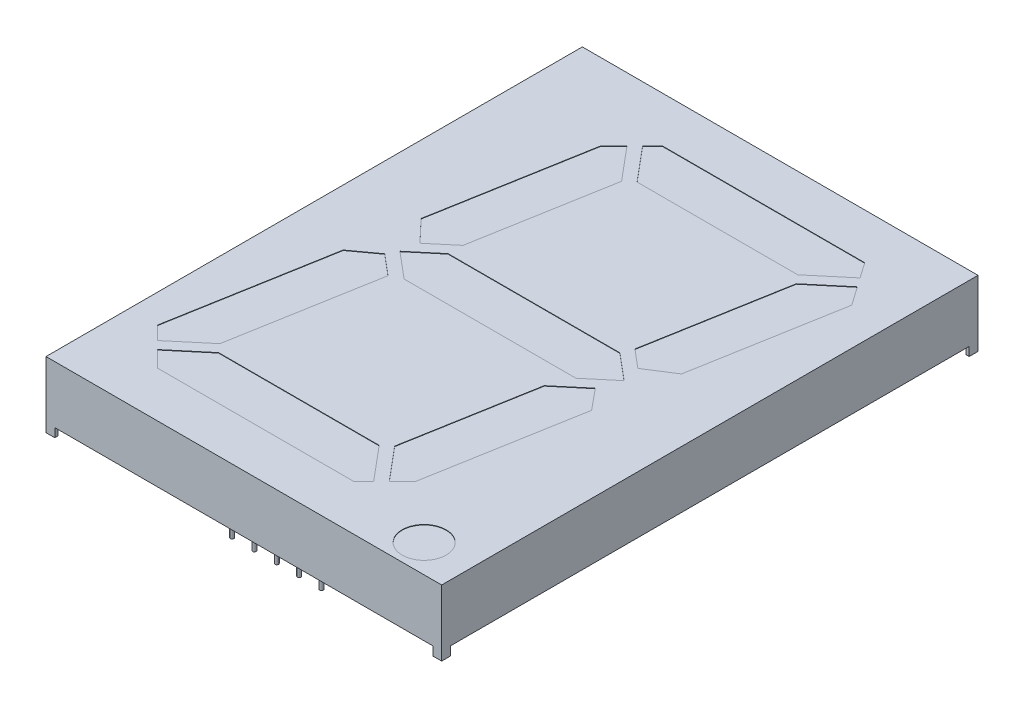
from build123d import *

# Parameters (mm, degrees)
SKETCH1_W          = 90
SKETCH1_H          = 122
EXTRUDE2_DEPTH     = 15
SKETCH2_W          = 43
SKETCH2_H          = 2
CUT_EXTRUDE2_DEPTH = 131.896905999
SKETCH3_W          = 118
SKETCH3_H          = 2
CUT_EXTRUDE3_DEPTH = 110.754270988
SKETCH6_R          = 5
CUT_EXTRUDE4_DEPTH = 0.1
SKETCH7_W          = 1.3
SKETCH7_H          = 1.3
CUT_EXTRUDE6_DEPTH = 2
SKETCH7_3_R        = 0.4
EXTRUDE3_DEPTH     = 2
SKETCH7_4_R        = 0.4
SKETCH7_4_W        = 1.3
SKETCH7_4_H        = 1.3
EXTRUDE4_DEPTH     = 7
SKETCH8_W          = 0.025316456
SKETCH8_H          = 0.026582279
CUT_EXTRUDE7_DEPTH = 0.01


with BuildPart() as part:
    # Sketch1 → Extrude2 (new body)
    with BuildSketch(Plane(origin=(0, 0, 0), x_dir=(1, 0, 0), z_dir=(0, 1, 0))):
        Rectangle(SKETCH1_W, SKETCH1_H)
    extrude(amount=-EXTRUDE2_DEPTH)

    # Sketch2 → Cut-Extrude2 (cut, through all)
    with BuildSketch(Plane.XY.offset(61)):
        with Locations((-21.5, -14)):
            Rectangle(SKETCH2_W, SKETCH2_H)
        with Locations((21.5, -14)):
            Rectangle(SKETCH2_W, SKETCH2_H)
    extrude(amount=-CUT_EXTRUDE2_DEPTH, mode=Mode.SUBTRACT)

    # Sketch3 → Cut-Extrude3 (cut, through all)
    with BuildSketch(Plane(origin=(45, 0, 0), x_dir=(0, 0, -1), z_dir=(1, 0, 0))):
        with Locations((0, -14)):
            Rectangle(SKETCH3_W, SKETCH3_H)
    extrude(amount=-CUT_EXTRUDE3_DEPTH, mode=Mode.SUBTRACT)

    # Sketch6 → Cut-Extrude4 (cut)
    with BuildSketch(Plane(origin=(0, 0, 0), x_dir=(-1, 0, 0), z_dir=(0, 1, 0))):
        Polygon((20.398345091, -46.545838518), (23.415251421, -43.528932188), (29.529286166, -8.854518093), (24.79846292, -3.852177728), (19.468462602, -8.324579029), (14.060787068, -38.993030976), align=None)
        Polygon((-29.633271507, -50.6), (16.344183609, -50.6), (18.623825555, -48.320358054), (12.14567596, -40.6), (-24.387261314, -40.6), (-32.102377523, -47.073751165), align=None)
        Polygon((26.725051062, 2.235578329), (32.183769067, 6.199802522), (38.516537786, 42.114718626), (35.472616354, 45.158640057), (27.757500146, 38.684888892), (22.025787113, 6.178728975), align=None)
        Polygon((19.541232037, -5), (25.5, 0), (19.541232037, 5), (-19.541232037, 5), (-25.5, 0), (-19.541232037, -5), align=None)
        Polygon((-36.516188743, -40.770175469), (-33.541796036, -45.018048485), (-25.994230339, -38.684888892), (-20.489778805, -7.46759298), (-24.644949642, -3.980990664), (-30.711693127, -7.851245007), align=None)
        Polygon((26.150531121, 40.6), (33.698096819, 46.933159593), (30.031256412, 50.6), (-14.580913802, 50.6), (-16.860555748, 48.320358054), (-10.382406153, 40.6), align=None)
        Polygon((-21.651981614, 43.528932188), (-27.647170865, 9.528524382), (-23.705923804, 4.768926898), (-17.399004207, 10.061060806), (-12.297517261, 38.993030976), (-18.635075284, 46.545838518), align=None)
        with Locations(Location((-34.625564691, 54.608682938, 0), (0, 0, 270))):
            Circle(SKETCH6_R)
    extrude(amount=-CUT_EXTRUDE4_DEPTH, mode=Mode.SUBTRACT)

    # Sketch7 → Cut-Extrude6 (cut)
    with BuildSketch(Plane.XZ.offset(15)):
        with Locations((-43.65, 59.65)):
            Rectangle(SKETCH7_W, SKETCH7_H)
        with Locations((-43.65, -59.65)):
            Rectangle(SKETCH7_W, SKETCH7_H)
        with Locations((43.65, -59.65)):
            Rectangle(SKETCH7_W, SKETCH7_H)
        with Locations((43.65, 59.65)):
            Rectangle(SKETCH7_W, SKETCH7_H)
    extrude(amount=-CUT_EXTRUDE6_DEPTH, mode=Mode.SUBTRACT)

    # Sketch7_3 → Extrude3 (add)
    with BuildSketch(Plane.XZ.offset(15)):
        with Locations(Location((-10.16, 53.5, 0), (0, 0, 270))):
            Circle(SKETCH7_3_R)
        with Locations(Location((-5.08, 53.5, 0), (0, 0, 270))):
            Circle(SKETCH7_3_R)
        with Locations(Location((0, 53.5, 0), (0, 0, 270))):
            Circle(SKETCH7_3_R)
        with Locations(Location((10.16, 53.5, 0), (0, 0, 270))):
            Circle(SKETCH7_3_R)
        with Locations(Location((5.08, 53.5, 0), (0, 0, 270))):
            Circle(SKETCH7_3_R)
        with Locations(Location((5.08, -53.5, 0), (0, 0, 270))):
            Circle(SKETCH7_3_R)
        with Locations(Location((10.16, -53.5, 0), (0, 0, 270))):
            Circle(SKETCH7_3_R)
        with Locations(Location((0, -53.5, 0), (0, 0, 270))):
            Circle(SKETCH7_3_R)
        with Locations(Location((-5.08, -53.5, 0), (0, 0, 270))):
            Circle(SKETCH7_3_R)
        with Locations(Location((-10.16, -53.5, 0), (0, 0, 270))):
            Circle(SKETCH7_3_R)
    extrude(amount=-EXTRUDE3_DEPTH)


with BuildPart() as extrude4_tool:
    # Sketch7_4 → Extrude4 (new body)
    with BuildSketch(Plane.XZ.offset(15)):
        with Locations(Location((-10.16, 53.5, 0), (0, 0, 270))):
            Circle(SKETCH7_4_R)
        with Locations(Location((-5.08, 53.5, 0), (0, 0, 270))):
            Circle(SKETCH7_4_R)
        with Locations(Location((0, 53.5, 0), (0, 0, 270))):
            Circle(SKETCH7_4_R)
        with Locations(Location((10.16, 53.5, 0), (0, 0, 270))):
            Circle(SKETCH7_4_R)
        with Locations(Location((5.08, 53.5, 0), (0, 0, 270))):
            Circle(SKETCH7_4_R)
        with Locations(Location((5.08, -53.5, 0), (0, 0, 270))):
            Circle(SKETCH7_4_R)
        with Locations(Location((10.16, -53.5, 0), (0, 0, 270))):
            Circle(SKETCH7_4_R)
        with Locations(Location((0, -53.5, 0), (0, 0, 270))):
            Circle(SKETCH7_4_R)
        with Locations(Location((-5.08, -53.5, 0), (0, 0, 270))):
            Circle(SKETCH7_4_R)
        with Locations(Location((-10.16, -53.5, 0), (0, 0, 270))):
            Circle(SKETCH7_4_R)
        with Locations((-43.65, 59.65)):
            Rectangle(SKETCH7_4_W, SKETCH7_4_H)
        with Locations((-43.65, -59.65)):
            Rectangle(SKETCH7_4_W, SKETCH7_4_H)
        with Locations((43.65, -59.65)):
            Rectangle(SKETCH7_4_W, SKETCH7_4_H)
        with Locations((43.65, 59.65)):
            Rectangle(SKETCH7_4_W, SKETCH7_4_H)
    extrude(amount=EXTRUDE4_DEPTH)


with BuildPart() as part_1:
    add(part.part)


with BuildPart() as part_2:
    # Extrude4: joined with extrude4_tool
    add(part_1.part.fuse(extrude4_tool.part, tol=0.00001))


with BuildPart() as extrude4_kept_piece:
    # of the separate pieces the step leaves, the one the design keeps (extrude4_pieces_kept)
    add(part_2.part.solids().sort_by_distance((-45, 0, -61))[0])

    # Sketch8 → Cut-Extrude7 (cut)
    with BuildSketch(Plane.XZ.offset(13)):
        Polygon((0.898234135, 43.968770201), (0.921691414, 44.043453745), (0.946434294, 44.043453745), (0.962850433, 43.993117511), (0.97837654, 44.043453745), (1.004108344, 44.043453745), (1.027348059, 43.968770201), (1.002170053, 43.968770201), (0.989175591, 44.020253587), (0.972759452, 43.968770201), (0.951260243, 43.968770201), (0.934942996, 44.020253587), (0.92212654, 43.968770201), align=None)
        Polygon((0.76405692, 43.968770201), (0.787514199, 44.043453745), (0.812257078, 44.043453745), (0.828673218, 43.993117511), (0.844199325, 44.043453745), (0.869931129, 44.043453745), (0.893170844, 43.968770201), (0.867992838, 43.968770201), (0.854998376, 44.020253587), (0.838582237, 43.968770201), (0.817083028, 43.968770201), (0.800765781, 44.020253587), (0.787949325, 43.968770201), align=None)
        Polygon((0.629879705, 43.968770201), (0.653336984, 44.043453745), (0.678079863, 44.043453745), (0.694496003, 43.993117511), (0.71002211, 44.043453745), (0.735753914, 44.043453745), (0.758993629, 43.968770201), (0.733815623, 43.968770201), (0.720821161, 44.020253587), (0.704405022, 43.968770201), (0.682905813, 43.968770201), (0.666588566, 44.020253587), (0.65377211, 43.968770201), align=None)
        with Locations((0.602031604, 44.030162606)):
            Rectangle(SKETCH8_W, SKETCH8_H)
        with BuildLine():
            add(Edge.make_bspline(
                [(0.485575908, 44.012282859), (0.485612436, 44.013504973), (0.485684165, 44.015904797), (0.486293327, 44.019412763), (0.487288851, 44.022736046), (0.488653189, 44.025898762), (0.490467177, 44.028854128), (0.492622191, 44.031672695), (0.495234105, 44.034256657), (0.498171141, 44.036695418), (0.501469069, 44.038877813), (0.50507169, 44.040777951), (0.50894201, 44.04240267), (0.513096031, 44.043734359), (0.517541609, 44.044725127), (0.522259385, 44.045448444), (0.527252734, 44.045921952), (0.530676322, 44.045963893), (0.532431129, 44.04598539)],
                knots=[0, 0, 0, 0, 0.907421153, 1.781872267, 2.635683434, 3.480115191, 4.332689235, 5.205575272, 6.109500117, 7.055808355, 8.037942167, 9.041423561, 10.07750834, 11.152467461, 12.277657752, 13.45734338, 14.696726425, 16, 16, 16, 16], degree=3))
            add(Edge.make_bspline(
                [(0.532431129, 44.04598539), (0.534449114, 44.045958125), (0.5383573, 44.045905322), (0.544024868, 44.045519949), (0.549288334, 44.044831999), (0.554186081, 44.043875419), (0.558790382, 44.042672134), (0.563223726, 44.04138149), (0.567505019, 44.039916909), (0.570278111, 44.038816773), (0.571651857, 44.038271783)],
                knots=[0, 0, 0, 0, 1.203182053, 2.33017619, 3.384818652, 4.366208123, 5.30340534, 6.221361684, 7.118890722, 8, 8, 8, 8], degree=3))
            Line((0.571651857, 44.038271783), (0.571651857, 44.014339821))
            Line((0.571651857, 44.014339821), (0.568803756, 44.014339821))
            add(Edge.make_bspline(
                [(0.568803756, 44.014339821), (0.567438192, 44.015420783), (0.564715083, 44.017576363), (0.560288125, 44.020344717), (0.555629113, 44.022717727), (0.550790719, 44.02470035), (0.545889351, 44.026275964), (0.541020283, 44.02740287), (0.5362513, 44.028142234), (0.533092979, 44.028223795), (0.531541097, 44.028263871)],
                knots=[0, 0, 0, 0, 1.030738938, 2.055426519, 3.085610749, 4.123842265, 5.148648843, 6.130724483, 7.081507926, 8, 8, 8, 8], degree=3))
            add(Edge.make_bspline(
                [(0.531541097, 44.028263871), (0.531112351, 44.028262571), (0.530194439, 44.028259786), (0.528725291, 44.028138471), (0.527068947, 44.028010627), (0.525288209, 44.027814513), (0.523501004, 44.027583368), (0.521840757, 44.027236901), (0.520339995, 44.02686775), (0.519433326, 44.026500484), (0.51900154, 44.02632558)],
                knots=[0, 0, 0, 0, 0.806537132, 1.726733348, 2.77251655, 3.932999672, 5.098049949, 6.161349231, 7.124375527, 8, 8, 8, 8], degree=3))
            add(Edge.make_bspline(
                [(0.51900154, 44.02632558), (0.518522054, 44.026097345), (0.517579762, 44.025648813), (0.516277231, 44.024834903), (0.515106746, 44.023940158), (0.514046044, 44.022978425), (0.513183648, 44.021815437), (0.512562487, 44.020416166), (0.512217917, 44.018766873), (0.512178845, 44.017591711), (0.512158186, 44.016970359)],
                knots=[0, 0, 0, 0, 1.02474257, 2.013837243, 2.958431669, 3.867978675, 4.769292696, 5.732237074, 6.800947934, 8, 8, 8, 8], degree=3))
            add(Edge.make_bspline(
                [(0.512158186, 44.016970359), (0.512189647, 44.016424492), (0.51225151, 44.015351158), (0.512833016, 44.013822729), (0.513717062, 44.012402593), (0.514996478, 44.011137257), (0.516610156, 44.010011145), (0.518541143, 44.009000382), (0.520814994, 44.008164624), (0.522452207, 44.007726752), (0.523313249, 44.007496466)],
                knots=[0, 0, 0, 0, 0.825427492, 1.623033598, 2.45033906, 3.348940377, 4.33183287, 5.428402891, 6.647546779, 8, 8, 8, 8], degree=3))
            add(Edge.make_bspline(
                [(0.523313249, 44.007496466), (0.52528249, 44.007051262), (0.529317702, 44.006138984), (0.535457515, 44.00495153), (0.541596217, 44.003725659), (0.545552474, 44.002511344), (0.547482553, 44.001918935)],
                knots=[0, 0, 0, 0, 0.976118991, 2.000185432, 3.024380873, 4, 4, 4, 4], degree=3))
            add(Edge.make_bspline(
                [(0.547482553, 44.001918935), (0.548520706, 44.001565212), (0.550541568, 44.000876657), (0.55344076, 43.999724009), (0.556084007, 43.998418875), (0.558541547, 43.997096837), (0.56073421, 43.995616779), (0.562728844, 43.99408402), (0.564481505, 43.992431215), (0.566007943, 43.990681723), (0.567350809, 43.988845361), (0.568504218, 43.98689822), (0.569465241, 43.98483177), (0.570288633, 43.982676373), (0.570899859, 43.980401838), (0.571322296, 43.978025421), (0.571620359, 43.975541934), (0.571641215, 43.973847599), (0.571651857, 43.972983017)],
                knots=[0, 0, 0, 0, 1.287376879, 2.505999703, 3.65855109, 4.746193839, 5.778582289, 6.760029101, 7.696159662, 8.601061861, 9.48181646, 10.363080883, 11.252765705, 12.153987336, 13.068239035, 14.012364187, 14.985753787, 16, 16, 16, 16], degree=3))
            add(Edge.make_bspline(
                [(0.571651857, 43.972983017), (0.571614557, 43.971826871), (0.57154115, 43.969551596), (0.5709397, 43.966222573), (0.569913189, 43.963073755), (0.56852683, 43.960070598), (0.566699337, 43.957256335), (0.564507214, 43.954578849), (0.561896904, 43.952086353), (0.558911577, 43.949787716), (0.555624729, 43.947708911), (0.552090724, 43.945872203), (0.548311873, 43.944365756), (0.544331988, 43.943084525), (0.540112595, 43.942132129), (0.535675625, 43.941412551), (0.531001762, 43.940999551), (0.527810351, 43.940948276), (0.526181129, 43.940922099)],
                knots=[0, 0, 0, 0, 0.894901293, 1.761149761, 2.608783409, 3.453876344, 4.314933854, 5.200038827, 6.12799933, 7.103249695, 8.113098521, 9.136064399, 10.182719798, 11.259667356, 12.370545059, 13.528828137, 14.738461593, 16, 16, 16, 16], degree=3))
            add(Edge.make_bspline(
                [(0.526181129, 43.940922099), (0.524512477, 43.940944492), (0.521178004, 43.940989239), (0.516196031, 43.941364209), (0.511238616, 43.94193071), (0.506367052, 43.942730165), (0.501684545, 43.94374782), (0.497267931, 43.944833779), (0.493188961, 43.946074168), (0.490615236, 43.947028214), (0.489373376, 43.947488555)],
                knots=[0, 0, 0, 0, 1.065379838, 2.128953261, 3.188461447, 4.250817766, 5.279613205, 6.247547721, 7.154416075, 8, 8, 8, 8], degree=3))
            Line((0.489373376, 43.947488555), (0.489373376, 43.970036023))
            Line((0.489373376, 43.970036023), (0.492201699, 43.970036023))
            add(Edge.make_bspline(
                [(0.492201699, 43.970036023), (0.493274658, 43.969235819), (0.495468889, 43.967599382), (0.499127641, 43.965513405), (0.503091702, 43.963563891), (0.507356603, 43.961842097), (0.511829144, 43.960421497), (0.51640669, 43.959392453), (0.521033755, 43.958753329), (0.524135346, 43.958680197), (0.525686667, 43.958643618)],
                knots=[0, 0, 0, 0, 0.89224925, 1.824673196, 2.804309561, 3.838364047, 4.890042674, 5.931526337, 6.965412421, 8, 8, 8, 8], degree=3))
            add(Edge.make_bspline(
                [(0.525686667, 43.958643618), (0.526781967, 43.958667828), (0.528971712, 43.958716229), (0.53224612, 43.959065483), (0.535480911, 43.959737224), (0.53752381, 43.96055156), (0.53854268, 43.960957701)],
                knots=[0, 0, 0, 0, 0.998993879, 1.997209027, 3.00113285, 4, 4, 4, 4], degree=3))
            add(Edge.make_bspline(
                [(0.53854268, 43.960957701), (0.538976159, 43.961159183), (0.539842828, 43.961562014), (0.541049832, 43.96233434), (0.542153135, 43.963264058), (0.543154141, 43.964316452), (0.544002197, 43.965485787), (0.544639857, 43.966755546), (0.545000676, 43.968117525), (0.545046513, 43.969051693), (0.545069578, 43.969521783)],
                knots=[0, 0, 0, 0, 1.005454979, 2.010239304, 3.005296729, 4.036100111, 5.060531193, 6.034954812, 7.011155677, 8, 8, 8, 8], degree=3))
            add(Edge.make_bspline(
                [(0.545069578, 43.969521783), (0.545034784, 43.970159714), (0.544968295, 43.971378742), (0.544368298, 43.973092438), (0.543370629, 43.97455555), (0.54221753, 43.975548543), (0.541100551, 43.976247303), (0.540060034, 43.976752542), (0.538860583, 43.977265965), (0.537483134, 43.977755163), (0.535947999, 43.978249209), (0.534239076, 43.978723879), (0.532356469, 43.979173438), (0.531040578, 43.97945959), (0.530354389, 43.979608808)],
                knots=[0, 0, 0, 0, 1.174343879, 2.244064321, 3.303704314, 4.407076671, 5.02483983, 5.732197225, 6.53898402, 7.431906431, 8.428480183, 9.514816237, 10.704066255, 12, 12, 12, 12], degree=3))
            add(Edge.make_bspline(
                [(0.530354389, 43.979608808), (0.528521764, 43.979985528), (0.524921061, 43.9807257), (0.519515986, 43.981819997), (0.514022932, 43.983132514), (0.510352382, 43.984261726), (0.508439832, 43.984850106)],
                knots=[0, 0, 0, 0, 0.995788186, 1.956503735, 2.935230479, 4, 4, 4, 4], degree=3))
            add(Edge.make_bspline(
                [(0.508439832, 43.984850106), (0.507493275, 43.985169347), (0.505641658, 43.985793835), (0.50300106, 43.986880153), (0.500553886, 43.98805401), (0.498287252, 43.989295979), (0.496211887, 43.990638413), (0.494325597, 43.992063746), (0.49262764, 43.993568529), (0.491138891, 43.995184249), (0.489810134, 43.996894597), (0.48869779, 43.99874521), (0.487702204, 44.000688739), (0.48694905, 44.002782182), (0.48632454, 44.00498071), (0.485902798, 44.007312644), (0.485608435, 44.009756862), (0.485586871, 44.011431461), (0.485575908, 44.012282859)],
                knots=[0, 0, 0, 0, 1.237326419, 2.420410185, 3.534642089, 4.598489486, 5.620241961, 6.59385002, 7.525152549, 8.426792174, 9.312230456, 10.203151844, 11.098070343, 12.012931196, 12.954244379, 13.926618287, 14.945853925, 16, 16, 16, 16], degree=3))
        make_face()
        with BuildLine():
            Line((0.393170844, 44.043453745), (0.417221477, 44.043453745))
            Line((0.417221477, 44.043453745), (0.417221477, 44.035621466))
            add(Edge.make_bspline(
                [(0.417221477, 44.035621466), (0.418314671, 44.036430261), (0.420422333, 44.037989606), (0.423596892, 44.040066667), (0.426615192, 44.04185109), (0.429545544, 44.043374207), (0.432551821, 44.044586378), (0.435789955, 44.045404758), (0.439291551, 44.045907482), (0.441718621, 44.045958844), (0.442973059, 44.04598539)],
                knots=[0, 0, 0, 0, 1.150945962, 2.219006967, 3.209666795, 4.118194914, 5.012574058, 5.946577101, 6.93868214, 8, 8, 8, 8], degree=3))
            add(Edge.make_bspline(
                [(0.442973059, 44.04598539), (0.443989334, 44.045962443), (0.445968315, 44.045917756), (0.448846615, 44.045576036), (0.451548581, 44.045027627), (0.454077418, 44.04425922), (0.456427118, 44.043256189), (0.458570798, 44.041984554), (0.460573375, 44.040551841), (0.462355322, 44.038845475), (0.463970868, 44.036947557), (0.465353439, 44.034815148), (0.466531144, 44.032482208), (0.467472244, 44.029930358), (0.468227332, 44.027172053), (0.468751265, 44.024192806), (0.469071857, 44.021005679), (0.469103797, 44.018810548), (0.469120211, 44.017682384)],
                knots=[0, 0, 0, 0, 1.108959949, 2.159465255, 3.158589008, 4.114545495, 5.039534357, 5.93921201, 6.830099133, 7.720870013, 8.624681761, 9.544731627, 10.487599671, 11.471264588, 12.508152322, 13.604835107, 14.769030043, 16, 16, 16, 16], degree=3))
            Line((0.469120211, 44.017682384), (0.469120211, 43.968770201))
            Line((0.469120211, 43.968770201), (0.445069578, 43.968770201))
            Line((0.445069578, 43.968770201), (0.445069578, 44.006349314))
            add(Edge.make_bspline(
                [(0.445069578, 44.006349314), (0.445067943, 44.007265785), (0.445064812, 44.009020001), (0.444982474, 44.011525808), (0.444861573, 44.01379398), (0.444722868, 44.015836009), (0.444469852, 44.01768276), (0.444092143, 44.019348921), (0.443621317, 44.020868522), (0.443156998, 44.021775224), (0.442933503, 44.022211656)],
                knots=[0, 0, 0, 0, 1.361401701, 2.605856924, 3.723918663, 4.735739235, 5.645738665, 6.489217889, 7.27279937, 8, 8, 8, 8], degree=3))
            add(Edge.make_bspline(
                [(0.442933503, 44.022211656), (0.442703494, 44.022610362), (0.442251317, 44.023394183), (0.441331053, 44.024400494), (0.44025221, 44.025244245), (0.438975007, 44.025902346), (0.43748544, 44.026392849), (0.435764581, 44.02677342), (0.433772839, 44.026945298), (0.432365371, 44.026979788), (0.431620211, 44.026998049)],
                knots=[0, 0, 0, 0, 0.849004071, 1.669068917, 2.503060811, 3.370079215, 4.310762265, 5.396376419, 6.621555549, 8, 8, 8, 8], degree=3))
            add(Edge.make_bspline(
                [(0.431620211, 44.026998049), (0.431079269, 44.02697821), (0.429967852, 44.026937448), (0.4282504, 44.026745907), (0.42646114, 44.026346748), (0.423942471, 44.025701804), (0.420777261, 44.024507949), (0.418417727, 44.023154802), (0.417221477, 44.022468777)],
                knots=[0, 0, 0, 0, 0.638062719, 1.310959128, 2.033463623, 2.796942592, 4.376095945, 6, 6, 6, 6], degree=3))
            Line((0.417221477, 44.022468777), (0.417221477, 43.968770201))
            Line((0.417221477, 43.968770201), (0.393170844, 43.968770201))
            Line((0.393170844, 43.968770201), (0.393170844, 44.043453745))
        make_face()
        with BuildLine():
            Line((0.29570249, 44.043453745), (0.319753123, 44.043453745))
            Line((0.319753123, 44.043453745), (0.319753123, 44.005874631))
            add(Edge.make_bspline(
                [(0.319753123, 44.005874631), (0.319778129, 44.004344641), (0.319828101, 44.00128715), (0.320104652, 43.997524056), (0.320489138, 43.994682516), (0.320856678, 43.992850928), (0.321288549, 43.991302811), (0.321700811, 43.990417049), (0.321889199, 43.990012289)],
                knots=[0, 0, 0, 0, 1.709111167, 3.415443484, 4.21113913, 4.910175115, 5.501990373, 6, 6, 6, 6], degree=3))
            add(Edge.make_bspline(
                [(0.321889199, 43.990012289), (0.32213366, 43.989614226), (0.322612959, 43.988833768), (0.32355031, 43.987820891), (0.324644094, 43.986991523), (0.32591527, 43.986312056), (0.327403379, 43.985832868), (0.329127296, 43.985480114), (0.331107481, 43.98526956), (0.332516309, 43.985241007), (0.333261825, 43.985225897)],
                knots=[0, 0, 0, 0, 0.860202684, 1.686548532, 2.528236983, 3.382486038, 4.33249885, 5.401154041, 6.624757403, 8, 8, 8, 8], degree=3))
            add(Edge.make_bspline(
                [(0.333261825, 43.985225897), (0.334392714, 43.985285997), (0.33670041, 43.985408639), (0.33957572, 43.986075305), (0.341893058, 43.986935269), (0.343750774, 43.987685705), (0.345658496, 43.988659805), (0.346938039, 43.989381247), (0.347601224, 43.989755169)],
                knots=[0, 0, 0, 0, 1.33818541, 2.730705359, 3.468371228, 4.262126284, 5.099261778, 6, 6, 6, 6], degree=3))
            Line((0.347601224, 43.989755169), (0.347601224, 44.043453745))
            Line((0.347601224, 44.043453745), (0.371651857, 44.043453745))
            Line((0.371651857, 44.043453745), (0.371651857, 43.968770201))
            Line((0.371651857, 43.968770201), (0.347601224, 43.968770201))
            Line((0.347601224, 43.968770201), (0.347601224, 43.976602479))
            add(Edge.make_bspline(
                [(0.347601224, 43.976602479), (0.346543817, 43.975796327), (0.344485513, 43.974227105), (0.341306275, 43.972186685), (0.338222377, 43.970387916), (0.335169367, 43.968875099), (0.332054412, 43.967668324), (0.328791654, 43.966857335), (0.325375248, 43.966313532), (0.323038533, 43.966263839), (0.321849642, 43.966238555)],
                knots=[0, 0, 0, 0, 1.126119141, 2.192057864, 3.198061997, 4.149848529, 5.076251285, 6.021887753, 6.99356175, 8, 8, 8, 8], degree=3))
            add(Edge.make_bspline(
                [(0.321849642, 43.966238555), (0.320853377, 43.966263955), (0.31890849, 43.966313541), (0.316073641, 43.966623093), (0.313402534, 43.967174316), (0.31090915, 43.967970173), (0.308573464, 43.968961532), (0.306399792, 43.970165511), (0.304413943, 43.971628792), (0.302585791, 43.973288731), (0.300946691, 43.975180029), (0.299549781, 43.977309407), (0.298345419, 43.979646327), (0.297396154, 43.982208964), (0.29660483, 43.984975236), (0.296100066, 43.987973866), (0.295742413, 43.991183752), (0.295716064, 43.993399902), (0.29570249, 43.994541561)],
                knots=[0, 0, 0, 0, 1.08828964, 2.12453497, 3.110382522, 4.062402335, 4.978696626, 5.878225494, 6.769849763, 7.667011675, 8.57076823, 9.495541561, 10.442454184, 11.436213583, 12.475881554, 13.580560132, 14.753614518, 16, 16, 16, 16], degree=3))
            Line((0.29570249, 43.994541561), (0.29570249, 44.043453745))
        make_face()
        Polygon((0.200765781, 44.043453745), (0.27291768, 44.043453745), (0.27291768, 43.943453745), (0.247601224, 43.943453745), (0.247601224, 44.024466403), (0.200765781, 44.024466403), align=None)
        Polygon((0.113424009, 44.043453745), (0.185575908, 44.043453745), (0.185575908, 43.943453745), (0.113424009, 43.943453745), (0.113424009, 43.962441087), (0.160259452, 43.962441087), (0.160259452, 43.980162606), (0.117221477, 43.980162606), (0.117221477, 43.999149947), (0.160259452, 43.999149947), (0.160259452, 44.024466403), (0.113424009, 44.024466403), align=None)
        with BuildLine():
            add(Edge.make_bspline(
                [(-0.003031687, 43.993552637), (-0.003012372, 43.994700326), (-0.00297412, 43.996973212), (-0.002678929, 44.000338019), (-0.002152903, 44.003603694), (-0.001473722, 44.006787943), (-0.000551216, 44.009866871), (0.000530498, 44.012874448), (0.001840144, 44.015779941), (0.003344996, 44.018581376), (0.004994468, 44.021253478), (0.006769217, 44.023773687), (0.008614997, 44.026156905), (0.010604309, 44.028351799), (0.012683491, 44.030393818), (0.014859019, 44.032284633), (0.017164084, 44.033988063), (0.018771246, 44.035010948), (0.019575116, 44.035522574)],
                knots=[0, 0, 0, 0, 1.105570398, 2.18947457, 3.250358341, 4.290584537, 5.323553275, 6.344225964, 7.367641686, 8.3905646, 9.405808457, 10.390761353, 11.358902336, 12.307789878, 13.241960776, 14.165076779, 15.082208636, 16, 16, 16, 16], degree=3))
            add(Edge.make_bspline(
                [(0.019575116, 44.035522574), (0.020814303, 44.036234895), (0.023299001, 44.037663172), (0.027283459, 44.039329011), (0.031405068, 44.040743234), (0.035764248, 44.041756674), (0.04040297, 44.04252651), (0.045407781, 44.043074681), (0.050814687, 44.043380184), (0.05454968, 44.043428666), (0.056481762, 44.043453745)],
                knots=[0, 0, 0, 0, 0.896321744, 1.797216976, 2.705381885, 3.628777036, 4.602292017, 5.655629376, 6.787275635, 8, 8, 8, 8], degree=3))
            Line((0.056481762, 44.043453745), (0.091905022, 44.043453745))
            Line((0.091905022, 44.043453745), (0.091905022, 43.943453745))
            Line((0.091905022, 43.943453745), (0.055473059, 43.943453745))
            add(Edge.make_bspline(
                [(0.055473059, 43.943453745), (0.053494363, 43.943470555), (0.049677704, 43.943502979), (0.044160387, 43.943917907), (0.039058049, 43.94452367), (0.034368469, 43.945417856), (0.030066019, 43.946532437), (0.026148728, 43.947920968), (0.022532495, 43.949413585), (0.020353959, 43.950688139), (0.019298218, 43.951305802)],
                knots=[0, 0, 0, 0, 1.267083275, 2.444046388, 3.541868212, 4.55639609, 5.499737919, 6.385160515, 7.217431253, 8, 8, 8, 8], degree=3))
            add(Edge.make_bspline(
                [(0.019298218, 43.951305802), (0.018447264, 43.951842342), (0.01675514, 43.952909256), (0.014353925, 43.954691108), (0.012124498, 43.956647185), (0.009995995, 43.958699004), (0.008016177, 43.960901891), (0.006172978, 43.963240598), (0.004469161, 43.965718692), (0.002911197, 43.968328161), (0.001490382, 43.971058213), (0.000301076, 43.973931272), (-0.000748273, 43.976909802), (-0.001553809, 43.980018764), (-0.002251723, 43.983226601), (-0.002686458, 43.986567945), (-0.002973069, 43.990020433), (-0.003011983, 43.992365323), (-0.003031687, 43.993552637)],
                knots=[0, 0, 0, 0, 0.964065863, 1.917049184, 2.86229036, 3.805247319, 4.749389377, 5.698846072, 6.657678277, 7.629829384, 8.610569287, 9.604676042, 10.607940105, 11.6349849, 12.681042988, 13.752616828, 14.862056989, 16, 16, 16, 16], degree=3))
        make_face()
        with BuildLine():
            add(Edge.make_bspline(
                [(0.023550591, 43.993394409), (0.023593893, 43.991815979), (0.023677506, 43.98876818), (0.024382901, 43.984372536), (0.025522151, 43.980329586), (0.026859843, 43.977217169), (0.028197235, 43.974943852), (0.029324758, 43.973345582), (0.030574424, 43.971831382), (0.031965034, 43.970422542), (0.033500218, 43.969115506), (0.035161477, 43.967886595), (0.036961518, 43.966757949), (0.038234549, 43.966097944), (0.038878914, 43.965763871)],
                knots=[0, 0, 0, 0, 1.694683197, 3.272273219, 4.767406206, 6.197615014, 6.895990032, 7.597410435, 8.296503208, 9.002591366, 9.720792421, 10.460154445, 11.220583224, 12, 12, 12, 12], degree=3))
            add(Edge.make_bspline(
                [(0.038878914, 43.965763871), (0.039553849, 43.965457357), (0.040891617, 43.964849824), (0.042961893, 43.964115738), (0.045054594, 43.96355341), (0.047248822, 43.963080988), (0.049725581, 43.962803852), (0.052648073, 43.962591175), (0.056104746, 43.962454248), (0.058591341, 43.962445677), (0.059923218, 43.962441087)],
                knots=[0, 0, 0, 0, 0.826913061, 1.638999358, 2.447478739, 3.243919028, 4.140906711, 5.225381046, 6.513851968, 8, 8, 8, 8], degree=3))
            Line((0.059923218, 43.962441087), (0.066588566, 43.962441087))
            Line((0.066588566, 43.962441087), (0.066588566, 44.024466403))
            Line((0.066588566, 44.024466403), (0.059923218, 44.024466403))
            add(Edge.make_bspline(
                [(0.059923218, 44.024466403), (0.059165026, 44.024461357), (0.057701291, 44.024451616), (0.055584838, 44.024412514), (0.053620076, 44.024352197), (0.051812725, 44.024280355), (0.050156589, 44.024165451), (0.048668755, 44.023996855), (0.047326404, 44.023852467), (0.04575877, 44.023585348), (0.043905621, 44.023168893), (0.041744355, 44.022490801), (0.039603823, 44.021640382), (0.038215249, 44.020955418), (0.037514199, 44.020609599)],
                knots=[0, 0, 0, 0, 1.186775798, 2.291144404, 3.313233901, 4.263515562, 5.122260739, 5.910868134, 6.60717912, 7.234883681, 8.398964994, 9.577230746, 10.776813768, 12, 12, 12, 12], degree=3))
            add(Edge.make_bspline(
                [(0.037514199, 44.020609599), (0.036930485, 44.020266123), (0.035782548, 44.019590639), (0.034138403, 44.018484776), (0.032651664, 44.017249777), (0.031245602, 44.015966679), (0.029992736, 44.014576225), (0.028819442, 44.013125745), (0.027809187, 44.011563352), (0.026564192, 44.009369822), (0.02534446, 44.006336453), (0.0243037, 44.002369909), (0.023667185, 43.998009899), (0.023590451, 43.994972317), (0.023550591, 43.993394409)],
                knots=[0, 0, 0, 0, 0.755109416, 1.485004392, 2.205961541, 2.908125208, 3.605307969, 4.290649036, 4.985852759, 5.676964147, 7.100721462, 8.614478074, 10.241350405, 12, 12, 12, 12], degree=3))
        make_face(mode=Mode.SUBTRACT)
        with Locations((-0.034677257, 44.030162606)):
            Rectangle(SKETCH8_W, SKETCH8_H)
        with BuildLine():
            add(Edge.make_bspline(
                [(-0.109321244, 44.04598539), (-0.107731139, 44.045963564), (-0.104610017, 44.045920722), (-0.100038572, 44.045444021), (-0.095673769, 44.044725554), (-0.091526151, 44.043707382), (-0.087619589, 44.04235104), (-0.083938536, 44.040733025), (-0.080549174, 44.038715219), (-0.078485444, 44.037138278), (-0.077458111, 44.03635327)],
                knots=[0, 0, 0, 0, 1.123606455, 2.205459211, 3.245124445, 4.248821949, 5.220056174, 6.165006393, 7.086533249, 8, 8, 8, 8], degree=3))
            add(Edge.make_bspline(
                [(-0.077458111, 44.03635327), (-0.076506364, 44.035498496), (-0.074606549, 44.033792253), (-0.072140616, 44.030820826), (-0.070017531, 44.027537782), (-0.068231978, 44.02393556), (-0.066801054, 44.020018831), (-0.065777921, 44.015774169), (-0.065158675, 44.011213388), (-0.06509151, 44.008065454), (-0.065057004, 44.006448207)],
                knots=[0, 0, 0, 0, 0.916457077, 1.82937027, 2.759194969, 3.714948755, 4.706655623, 5.743329475, 6.840637961, 8, 8, 8, 8], degree=3))
            add(Edge.make_bspline(
                [(-0.065057004, 44.006448207), (-0.065095764, 44.00474498), (-0.065170887, 44.0014439), (-0.065834647, 43.996671712), (-0.066904259, 43.992254032), (-0.068441817, 43.988202123), (-0.070372259, 43.984508932), (-0.072636752, 43.981137097), (-0.075257278, 43.978094173), (-0.077264416, 43.976348733), (-0.078269029, 43.975475106)],
                knots=[0, 0, 0, 0, 1.171797512, 2.271099083, 3.308930235, 4.294129479, 5.24602549, 6.17106565, 7.084581485, 8, 8, 8, 8], degree=3))
            add(Edge.make_bspline(
                [(-0.078269029, 43.975475106), (-0.079294943, 43.974706644), (-0.081359161, 43.97316044), (-0.084762006, 43.971257829), (-0.088389696, 43.969669635), (-0.092211431, 43.968392916), (-0.096186417, 43.967438299), (-0.100249971, 43.966745632), (-0.104393772, 43.96631695), (-0.107184153, 43.966264813), (-0.108589441, 43.966238555)],
                knots=[0, 0, 0, 0, 0.952046378, 1.915591786, 2.889970712, 3.892742799, 4.906722985, 5.925995921, 6.955492795, 8, 8, 8, 8], degree=3))
            add(Edge.make_bspline(
                [(-0.108589441, 43.966238555), (-0.109836245, 43.966254952), (-0.112287885, 43.966287196), (-0.115886725, 43.966617799), (-0.119344684, 43.967119736), (-0.122651602, 43.967858309), (-0.125818599, 43.968779926), (-0.128872738, 43.969811988), (-0.131831971, 43.970947219), (-0.133732615, 43.971831496), (-0.134677257, 43.972270992)],
                knots=[0, 0, 0, 0, 1.107549047, 2.177816721, 3.208424937, 4.210433793, 5.185680559, 6.13785309, 7.074491882, 8, 8, 8, 8], degree=3))
            Line((-0.134677257, 43.972270992), (-0.134677257, 43.992820833))
            Line((-0.134677257, 43.992820833), (-0.131334694, 43.992820833))
            add(Edge.make_bspline(
                [(-0.131334694, 43.992820833), (-0.130834116, 43.992404947), (-0.129749091, 43.991503495), (-0.12798226, 43.990056907), (-0.12581194, 43.988556617), (-0.12416491, 43.987661992), (-0.123284852, 43.987183966)],
                knots=[0, 0, 0, 0, 0.792743043, 1.718305972, 2.780820752, 4, 4, 4, 4], degree=3))
            add(Edge.make_bspline(
                [(-0.123284852, 43.987183966), (-0.122355917, 43.986745328), (-0.120450008, 43.985845368), (-0.1179068, 43.98496798), (-0.11570362, 43.984442611), (-0.11388996, 43.984177045), (-0.111955663, 43.983990187), (-0.110620517, 43.983970296), (-0.109934377, 43.983960074)],
                knots=[0, 0, 0, 0, 1.332360773, 2.733622135, 3.480580446, 4.268165618, 5.10999921, 6, 6, 6, 6], degree=3))
            add(Edge.make_bspline(
                [(-0.109934377, 43.983960074), (-0.109168738, 43.983979405), (-0.107684966, 43.984016867), (-0.105524598, 43.984296914), (-0.103499981, 43.984765007), (-0.101611943, 43.985442951), (-0.099858112, 43.986294717), (-0.098238088, 43.987336163), (-0.096744656, 43.988559434), (-0.095425714, 43.990001066), (-0.0942329, 43.991580806), (-0.093213723, 43.993314973), (-0.09230126, 43.995161558), (-0.091606324, 43.997166011), (-0.091046585, 43.999294786), (-0.090657656, 44.001557906), (-0.090415697, 44.003957416), (-0.09038778, 44.005603724), (-0.09037346, 44.006448207)],
                knots=[0, 0, 0, 0, 1.087372478, 2.107277257, 3.088614887, 4.033572876, 4.950837204, 5.852283781, 6.763600506, 7.684681617, 8.621202104, 9.570420019, 10.537986648, 11.542161979, 12.577980734, 13.661919757, 14.800668594, 16, 16, 16, 16], degree=3))
            add(Edge.make_bspline(
                [(-0.09037346, 44.006448207), (-0.090388234, 44.007312363), (-0.09041694, 44.008991376), (-0.090650454, 44.011432987), (-0.091066345, 44.013714418), (-0.091637593, 44.015839738), (-0.092361941, 44.017805756), (-0.093267058, 44.019603153), (-0.094303415, 44.02125996), (-0.095547973, 44.022722572), (-0.096911857, 44.024038893), (-0.098426748, 44.025175028), (-0.100085988, 44.026123173), (-0.101868168, 44.026927636), (-0.103801209, 44.027506034), (-0.105857745, 44.027942726), (-0.1080473, 44.028231283), (-0.109557654, 44.028252846), (-0.110329947, 44.028263871)],
                knots=[0, 0, 0, 0, 1.230336593, 2.390482092, 3.487897344, 4.52859895, 5.520747884, 6.465347575, 7.38981449, 8.296085817, 9.192433006, 10.084246191, 10.984321635, 11.908883871, 12.862027947, 13.850751296, 14.901019963, 16, 16, 16, 16], degree=3))
            add(Edge.make_bspline(
                [(-0.110329947, 44.028263871), (-0.111055712, 44.028255122), (-0.112470563, 44.028238064), (-0.114537564, 44.02802851), (-0.116495069, 44.027721739), (-0.118328211, 44.027281786), (-0.120030943, 44.026769235), (-0.121587277, 44.02619629), (-0.123000253, 44.025593164), (-0.123861543, 44.025125408), (-0.124273776, 44.02490153)],
                knots=[0, 0, 0, 0, 1.201052708, 2.34140671, 3.435973211, 4.479046096, 5.459661032, 6.378175262, 7.223757638, 8, 8, 8, 8], degree=3))
            add(Edge.make_bspline(
                [(-0.124273776, 44.02490153), (-0.124973982, 44.024471635), (-0.126328548, 44.023639993), (-0.128167276, 44.022238427), (-0.129812145, 44.020824167), (-0.130836657, 44.01986795), (-0.131334694, 44.019403112)],
                knots=[0, 0, 0, 0, 1.098601379, 2.125273733, 3.088655601, 4, 4, 4, 4], degree=3))
            Line((-0.131334694, 44.019403112), (-0.134677257, 44.019403112))
            Line((-0.134677257, 44.019403112), (-0.134677257, 44.040111182))
            add(Edge.make_bspline(
                [(-0.134677257, 44.040111182), (-0.133731867, 44.040548676), (-0.13184086, 44.041423769), (-0.128926281, 44.042577641), (-0.125938308, 44.043545802), (-0.122889935, 44.044448882), (-0.119717852, 44.045137244), (-0.116394822, 44.045630367), (-0.112913323, 44.045931279), (-0.110534934, 44.045967107), (-0.109321244, 44.04598539)],
                knots=[0, 0, 0, 0, 0.952012952, 1.904254716, 2.862729541, 3.822037426, 4.808956931, 5.82647221, 6.890850784, 8, 8, 8, 8], degree=3))
        make_face()
        with BuildLine():
            add(Edge.make_bspline(
                [(-0.22708232, 44.00615153), (-0.227057625, 44.007656436), (-0.227009487, 44.010589902), (-0.22647017, 44.014861693), (-0.22565739, 44.01889769), (-0.224484859, 44.022684899), (-0.223004466, 44.026242173), (-0.221153527, 44.029531966), (-0.218982523, 44.032585196), (-0.216491486, 44.03537508), (-0.213690283, 44.037873591), (-0.210616101, 44.040068844), (-0.207242274, 44.041882286), (-0.203627963, 44.043394376), (-0.199743312, 44.044563611), (-0.195589092, 44.045376328), (-0.191171958, 44.045911799), (-0.188133539, 44.045960451), (-0.186575991, 44.04598539)],
                knots=[0, 0, 0, 0, 1.120167703, 2.183507516, 3.201345984, 4.182878364, 5.131270247, 6.065524964, 6.98789854, 7.91635504, 8.84481154, 9.778033504, 10.722808862, 11.691211189, 12.691525459, 13.738229926, 14.840575679, 16, 16, 16, 16], degree=3))
            add(Edge.make_bspline(
                [(-0.186575991, 44.04598539), (-0.18501847, 44.045960368), (-0.181980104, 44.045911556), (-0.177562595, 44.045377225), (-0.1734035, 44.044559274), (-0.169514193, 44.043403173), (-0.165905447, 44.041876624), (-0.162535581, 44.040069576), (-0.159461815, 44.037873382), (-0.15666033, 44.035375191), (-0.154170011, 44.032584964), (-0.15199642, 44.029532782), (-0.150154006, 44.026236828), (-0.148636153, 44.022693782), (-0.147502828, 44.018892944), (-0.146679365, 44.014862502), (-0.146143157, 44.010589683), (-0.146094582, 44.007656361), (-0.146069662, 44.00615153)],
                knots=[0, 0, 0, 0, 1.15937715, 2.261678054, 3.308339936, 4.313313916, 5.277148057, 6.221884977, 7.155068972, 8.083487698, 9.011906424, 9.934242473, 10.868459181, 11.818729666, 12.798784262, 13.81658132, 14.879877871, 16, 16, 16, 16], degree=3))
            add(Edge.make_bspline(
                [(-0.146069662, 44.00615153), (-0.146094764, 44.004640097), (-0.146143807, 44.001687069), (-0.146679474, 43.997388322), (-0.147496437, 43.993327225), (-0.148661968, 43.989514675), (-0.150168246, 43.985952199), (-0.152015191, 43.98264601), (-0.154210946, 43.979599236), (-0.156720381, 43.976809072), (-0.159533147, 43.974314544), (-0.162620645, 43.972136439), (-0.165984185, 43.970327646), (-0.169584538, 43.968799881), (-0.173472199, 43.967667335), (-0.177608826, 43.966849179), (-0.182006308, 43.966311269), (-0.185025034, 43.966263234), (-0.186575991, 43.966238555)],
                knots=[0, 0, 0, 0, 1.123883205, 2.195836198, 3.217400301, 4.202580581, 5.156396106, 6.089661422, 7.013912723, 7.944661364, 8.875797629, 9.805201257, 10.748976071, 11.711828658, 12.709674189, 13.755270167, 14.846705509, 16, 16, 16, 16], degree=3))
            add(Edge.make_bspline(
                [(-0.186575991, 43.966238555), (-0.188146729, 43.966263277), (-0.191204893, 43.96631141), (-0.195648305, 43.966847613), (-0.199822144, 43.967660617), (-0.20372077, 43.968827014), (-0.20734652, 43.970338427), (-0.210706595, 43.972173085), (-0.213777902, 43.974375143), (-0.216565156, 43.976882299), (-0.219045397, 43.979687701), (-0.221214314, 43.982737324), (-0.223021531, 43.98605704), (-0.224503302, 43.989611908), (-0.225675474, 43.993405678), (-0.226496459, 43.997439783), (-0.22700245, 44.00171478), (-0.227055234, 44.00464691), (-0.22708232, 44.00615153)],
                knots=[0, 0, 0, 0, 1.167358552, 2.272800965, 3.322628764, 4.326027541, 5.29287265, 6.238482395, 7.166210353, 8.096447471, 9.020151799, 9.945039072, 10.873038967, 11.824425184, 12.804379233, 13.820580988, 14.881633558, 16, 16, 16, 16], degree=3))
        make_face()
        with BuildLine():
            add(Edge.make_bspline(
                [(-0.197375042, 44.024644409), (-0.197730045, 44.024144328), (-0.198452518, 44.023126604), (-0.199328326, 44.02142195), (-0.200106904, 44.019589497), (-0.200727377, 44.01756187), (-0.201211222, 44.015266757), (-0.201519677, 44.012619202), (-0.20175002, 44.009583809), (-0.201760375, 44.007431078), (-0.201765865, 44.006289979)],
                knots=[0, 0, 0, 0, 0.765001119, 1.556867793, 2.387180485, 3.249178546, 4.200309879, 5.312433676, 6.575401142, 8, 8, 8, 8], degree=3))
            add(Edge.make_bspline(
                [(-0.201765865, 44.006289979), (-0.201748131, 44.005215105), (-0.201714155, 44.003155764), (-0.201528371, 44.000195899), (-0.201176911, 43.997506401), (-0.200683394, 43.995081693), (-0.200075804, 43.992909623), (-0.199341002, 43.990977295), (-0.198507565, 43.98926334), (-0.19782181, 43.988258219), (-0.197493713, 43.987777321)],
                knots=[0, 0, 0, 0, 1.337015307, 2.56157572, 3.686511827, 4.707709802, 5.636963675, 6.488272502, 7.276717686, 8, 8, 8, 8], degree=3))
            add(Edge.make_bspline(
                [(-0.197493713, 43.987777321), (-0.197156325, 43.98733823), (-0.19649446, 43.986476851), (-0.19531967, 43.985391963), (-0.19404815, 43.984501701), (-0.192683689, 43.983805718), (-0.191223499, 43.983323999), (-0.189721138, 43.98296751), (-0.188164956, 43.982742107), (-0.187110761, 43.982710357), (-0.186575991, 43.982694251)],
                knots=[0, 0, 0, 0, 1.058488312, 2.076474566, 3.046302828, 4.022760093, 4.996603884, 5.982315336, 6.976474174, 8, 8, 8, 8], degree=3))
            add(Edge.make_bspline(
                [(-0.186575991, 43.982694251), (-0.186048059, 43.982705197), (-0.185015442, 43.982726608), (-0.183512776, 43.98290629), (-0.182101828, 43.98320088), (-0.180761954, 43.983618813), (-0.17946998, 43.984214296), (-0.178235636, 43.98507072), (-0.177019699, 43.986146051), (-0.176281451, 43.986996569), (-0.175895611, 43.987441087)],
                knots=[0, 0, 0, 0, 1.041978199, 2.038073998, 2.982578265, 3.884042198, 4.804014415, 5.778706634, 6.839057036, 8, 8, 8, 8], degree=3))
            add(Edge.make_bspline(
                [(-0.175895611, 43.987441087), (-0.175562126, 43.987915713), (-0.174860483, 43.988914313), (-0.173977507, 43.990618833), (-0.173246154, 43.992580754), (-0.172553914, 43.994764495), (-0.172035649, 43.997235643), (-0.171634911, 43.999988921), (-0.171434196, 44.003043348), (-0.171402621, 44.005175565), (-0.171386118, 44.006289979)],
                knots=[0, 0, 0, 0, 0.706185926, 1.485796665, 2.33004681, 3.254820698, 4.274138656, 5.402098861, 6.642194297, 8, 8, 8, 8], degree=3))
            add(Edge.make_bspline(
                [(-0.171386118, 44.006289979), (-0.171395274, 44.007292439), (-0.171413003, 44.009233544), (-0.171611788, 44.012039981), (-0.171940905, 44.014643736), (-0.172416067, 44.017034365), (-0.17299682, 44.01922325), (-0.173728909, 44.021181457), (-0.174568396, 44.022929175), (-0.175263604, 44.023952857), (-0.175598934, 44.024446625)],
                knots=[0, 0, 0, 0, 1.27086383, 2.460826804, 3.565079772, 4.596261907, 5.549370831, 6.432852304, 7.244093885, 8, 8, 8, 8], degree=3))
            add(Edge.make_bspline(
                [(-0.175598934, 44.024446625), (-0.175939424, 44.02486324), (-0.176610722, 44.025684623), (-0.177760654, 44.02676678), (-0.179038087, 44.027633275), (-0.180400165, 44.028337424), (-0.181858898, 44.028865097), (-0.18340534, 44.02927234), (-0.185060606, 44.02947992), (-0.186193129, 44.029512824), (-0.186773776, 44.029529694)],
                knots=[0, 0, 0, 0, 1.011466313, 1.994169768, 2.957274081, 3.905656451, 4.870834188, 5.869371193, 6.907620549, 8, 8, 8, 8], degree=3))
            add(Edge.make_bspline(
                [(-0.186773776, 44.029529694), (-0.187775185, 44.029478045), (-0.189775321, 44.029374886), (-0.19218647, 44.028638077), (-0.19398816, 44.027786021), (-0.195240151, 44.026931561), (-0.196389089, 44.025888129), (-0.197043176, 44.025063037), (-0.197375042, 44.024644409)],
                knots=[0, 0, 0, 0, 1.484683483, 2.96539121, 3.705388955, 4.438554905, 5.207767564, 6, 6, 6, 6], degree=3))
        make_face(mode=Mode.SUBTRACT)
        with BuildLine():
            Line((-0.318221561, 43.989755169), (-0.318221561, 44.043453745))
            Line((-0.318221561, 44.043453745), (-0.294170928, 44.043453745))
            Line((-0.294170928, 44.043453745), (-0.294170928, 44.005597732))
            add(Edge.make_bspline(
                [(-0.294170928, 44.005597732), (-0.294165461, 44.004707698), (-0.294154973, 44.003000066), (-0.29412195, 44.000540453), (-0.294041678, 43.998291848), (-0.293934139, 43.996245649), (-0.293747194, 43.994386184), (-0.293435855, 43.992711349), (-0.293014358, 43.991205823), (-0.292606008, 43.990304875), (-0.292410643, 43.98987384)],
                knots=[0, 0, 0, 0, 1.339742217, 2.570446543, 3.702449567, 4.726327994, 5.654556215, 6.512888379, 7.288529137, 8, 8, 8, 8], degree=3))
            add(Edge.make_bspline(
                [(-0.292410643, 43.98987384), (-0.292200636, 43.98948863), (-0.29178435, 43.988725048), (-0.290917494, 43.987754897), (-0.289902177, 43.986950863), (-0.288738501, 43.986275291), (-0.287343482, 43.985815245), (-0.285735483, 43.9854541), (-0.283870051, 43.985277616), (-0.282548002, 43.985243785), (-0.281848934, 43.985225897)],
                knots=[0, 0, 0, 0, 0.859137151, 1.703023591, 2.531884144, 3.395689496, 4.329139829, 5.403231912, 6.626892925, 8, 8, 8, 8], degree=3))
            add(Edge.make_bspline(
                [(-0.281848934, 43.985225897), (-0.281261496, 43.985248923), (-0.280081319, 43.985295184), (-0.278326755, 43.985544586), (-0.276600819, 43.986014818), (-0.274382518, 43.986859155), (-0.271780793, 43.988096447), (-0.269804412, 43.989216716), (-0.268854472, 43.989755169)],
                knots=[0, 0, 0, 0, 0.759272211, 1.52539342, 2.28366165, 3.065252147, 4.589423829, 6, 6, 6, 6], degree=3))
            Line((-0.268854472, 43.989755169), (-0.268854472, 44.043453745))
            Line((-0.268854472, 44.043453745), (-0.244803839, 44.043453745))
            Line((-0.244803839, 44.043453745), (-0.244803839, 43.968770201))
            Line((-0.244803839, 43.968770201), (-0.268854472, 43.968770201))
            Line((-0.268854472, 43.968770201), (-0.268854472, 43.976602479))
            add(Edge.make_bspline(
                [(-0.268854472, 43.976602479), (-0.269875211, 43.975820517), (-0.271857073, 43.974302262), (-0.274877937, 43.972260992), (-0.277822211, 43.970473053), (-0.28072438, 43.968939907), (-0.283679727, 43.967713511), (-0.286768827, 43.966870001), (-0.290012386, 43.966339703), (-0.292230557, 43.966272681), (-0.29336001, 43.966238555)],
                knots=[0, 0, 0, 0, 1.13602934, 2.205708752, 3.219814904, 4.178719654, 5.103700513, 6.040802208, 7.002410817, 8, 8, 8, 8], degree=3))
            add(Edge.make_bspline(
                [(-0.29336001, 43.966238555), (-0.294563159, 43.966270478), (-0.29691463, 43.966332871), (-0.300327875, 43.966999636), (-0.30353615, 43.968012473), (-0.306510716, 43.96946952), (-0.309213898, 43.971333493), (-0.311613016, 43.973605358), (-0.313726077, 43.976253461), (-0.314816411, 43.978264777), (-0.31537346, 43.979292352)],
                knots=[0, 0, 0, 0, 1.06596181, 2.083348439, 3.072786094, 4.043114605, 5.009947443, 5.973893017, 6.964867644, 8, 8, 8, 8], degree=3))
            add(Edge.make_bspline(
                [(-0.31537346, 43.979292352), (-0.316555546, 43.978315393), (-0.318859204, 43.976411488), (-0.322412798, 43.973868792), (-0.325891955, 43.971614492), (-0.329332207, 43.969704779), (-0.332727858, 43.96815989), (-0.336106985, 43.96705429), (-0.339455766, 43.966370844), (-0.341689026, 43.966282142), (-0.342786434, 43.966238555)],
                knots=[0, 0, 0, 0, 1.188124574, 2.315425566, 3.384037189, 4.39937427, 5.362203716, 6.270239573, 7.150007311, 8, 8, 8, 8], degree=3))
            add(Edge.make_bspline(
                [(-0.342786434, 43.966238555), (-0.343769686, 43.966261941), (-0.345682831, 43.966307443), (-0.348465368, 43.966642586), (-0.351061623, 43.967213864), (-0.35348535, 43.96800623), (-0.35572129, 43.969034946), (-0.357784419, 43.970282124), (-0.359632501, 43.971792623), (-0.361325286, 43.973491313), (-0.36281443, 43.975427982), (-0.364099068, 43.97756603), (-0.365169939, 43.979912817), (-0.366059281, 43.982447513), (-0.366747428, 43.985188918), (-0.367236764, 43.988132071), (-0.367535186, 43.991271933), (-0.367570527, 43.993433292), (-0.367588649, 43.994541561)],
                knots=[0, 0, 0, 0, 1.099136554, 2.138625863, 3.127574945, 4.066908717, 4.983764051, 5.873707737, 6.754323387, 7.645578618, 8.549333854, 9.478432518, 10.428234329, 11.428300305, 12.477672891, 13.584002437, 14.761160362, 16, 16, 16, 16], degree=3))
            Line((-0.367588649, 43.994541561), (-0.367588649, 44.043453745))
            Line((-0.367588649, 44.043453745), (-0.343538016, 44.043453745))
            Line((-0.343538016, 44.043453745), (-0.343538016, 44.005597732))
            add(Edge.make_bspline(
                [(-0.343538016, 44.005597732), (-0.343532343, 44.004701114), (-0.343521455, 44.002980315), (-0.343491207, 44.000507398), (-0.34340266, 43.998252921), (-0.343320939, 43.996206569), (-0.343155056, 43.994360533), (-0.342863088, 43.992696386), (-0.342435907, 43.991210451), (-0.342043876, 43.990305552), (-0.341856846, 43.98987384)],
                knots=[0, 0, 0, 0, 1.350818449, 2.592504867, 3.725474742, 4.749698069, 5.67770978, 6.515438232, 7.29174147, 8, 8, 8, 8], degree=3))
            add(Edge.make_bspline(
                [(-0.341856846, 43.98987384), (-0.34165339, 43.989488986), (-0.341250578, 43.988727032), (-0.340402603, 43.987749825), (-0.339383919, 43.986945768), (-0.338203205, 43.986276208), (-0.336783527, 43.985812171), (-0.335154257, 43.985458765), (-0.333263776, 43.985275209), (-0.331928364, 43.985243051), (-0.331216023, 43.985225897)],
                knots=[0, 0, 0, 0, 0.846272708, 1.675499002, 2.498229298, 3.366836971, 4.305509618, 5.396757786, 6.611368595, 8, 8, 8, 8], degree=3))
            add(Edge.make_bspline(
                [(-0.331216023, 43.985225897), (-0.330214903, 43.985272826), (-0.328201094, 43.985367228), (-0.325719592, 43.986087934), (-0.323690899, 43.986894471), (-0.322007297, 43.987707689), (-0.320148579, 43.988641624), (-0.318883747, 43.989372519), (-0.318221561, 43.989755169)],
                knots=[0, 0, 0, 0, 1.291206289, 2.597335145, 3.312416795, 4.112753053, 5.011956018, 6, 6, 6, 6], degree=3))
        make_face()
    extrude(amount=-CUT_EXTRUDE7_DEPTH, mode=Mode.SUBTRACT)


solid = extrude4_kept_piece.part
